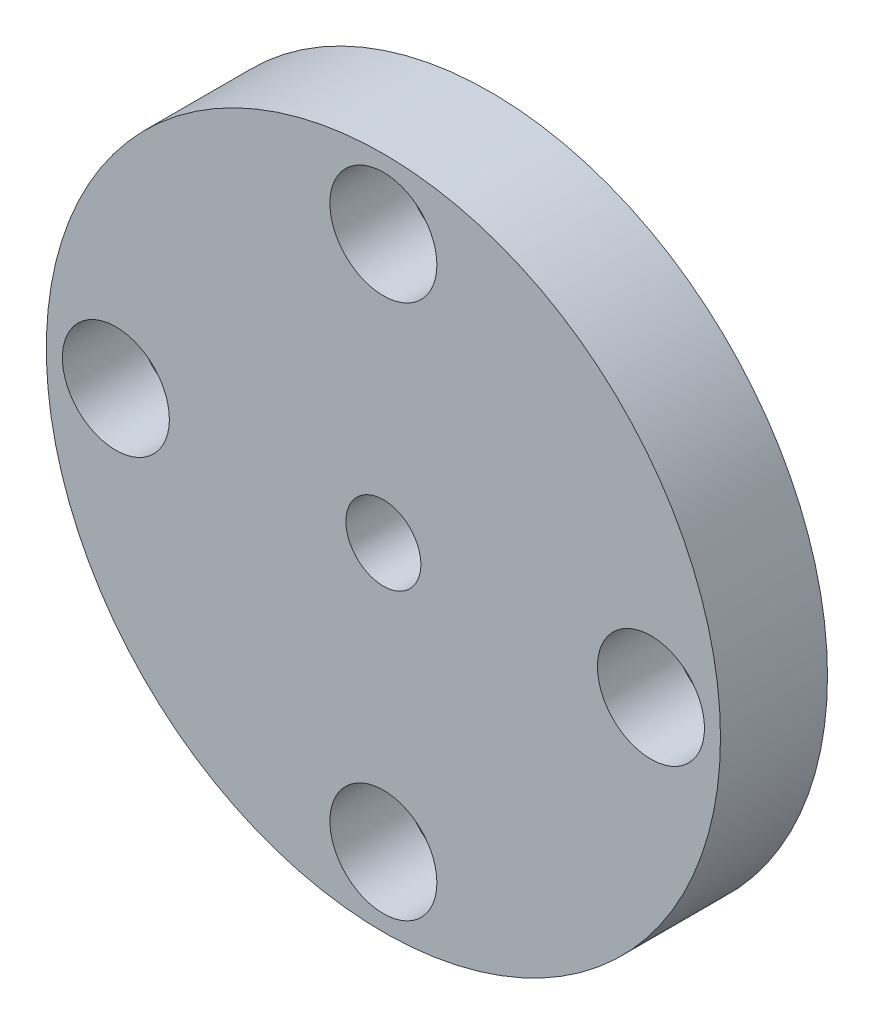
from build123d import *

# Parameters (mm, degrees)
SKETCH1_R               = 31.5
BOSS_EXTRUDE1_DEPTH     = 10
SKETCH1_3_R             = 15.5
BOSS_EXTRUDE2_DEPTH     = 4
SKETCH2_R               = 3.5
CUT_EXTRUDE1_DEPTH      = 47.695824224
SKETCH3_R               = 5
SKETCH3_R_2             = 3
CUT_EXTRUDE2_DEPTH      = 7
CUT_EXTRUDE3_DEPTH      = 47.695824224
CUT_EXTRUDE3_DEPTH_BACK = 47.695824224
SKETCH3_4_R             = 3


with BuildPart() as part:
    # Sketch1 → Boss-Extrude1 (new body)
    with BuildSketch(Plane.XY):
        Circle(SKETCH1_R)
    extrude(amount=BOSS_EXTRUDE1_DEPTH)

    # Sketch1_3 → Boss-Extrude2 (add)
    with BuildSketch(Plane.XY):
        Circle(SKETCH1_3_R)
    extrude(amount=-BOSS_EXTRUDE2_DEPTH)

    # Sketch2 → Cut-Extrude1 (cut, through all)
    with BuildSketch(Plane(origin=(0, 0, -4), x_dir=(-1, 0, 0), z_dir=(0, 0, -1))):
        Circle(SKETCH2_R)
    extrude(amount=-CUT_EXTRUDE1_DEPTH, mode=Mode.SUBTRACT)

    # Sketch3 → Cut-Extrude2 (cut)
    # profile 1 of 4: a face of its own
    with BuildSketch(Plane.XY.offset(10)):
        with Locations((25, 0)):
            Circle(SKETCH3_R)
    # profile 2 of 4: a face of its own
    with BuildSketch(Plane.XY.offset(10)):
        with Locations((0, 25)):
            Circle(SKETCH3_R)
        with Locations((0, 25)):
            Circle(SKETCH3_R_2, mode=Mode.SUBTRACT)
    # profile 3 of 4: a face of its own
    with BuildSketch(Plane.XY.offset(10)):
        with Locations((0, -25)):
            Circle(SKETCH3_R)
        with Locations((0, -25)):
            Circle(SKETCH3_R_2, mode=Mode.SUBTRACT)
    # profile 4 of 4: a face of its own
    with BuildSketch(Plane.XY.offset(10)):
        with Locations((-25, 0)):
            Circle(SKETCH3_R)
        with Locations((-25, 0)):
            Circle(SKETCH3_R_2, mode=Mode.SUBTRACT)
    extrude(amount=-CUT_EXTRUDE2_DEPTH, mode=Mode.SUBTRACT)

    # Sketch3_4 → Cut-Extrude3 (cut, two sides: drawn at the far end of the back side and taken through both)
    with BuildSketch(Plane.XY.offset(10).offset(-CUT_EXTRUDE3_DEPTH_BACK)):
        with Locations((25, 0)):
            Circle(SKETCH3_4_R)
        with Locations((0, 25)):
            Circle(SKETCH3_4_R)
        with Locations((0, -25)):
            Circle(SKETCH3_4_R)
        with Locations((-25, 0)):
            Circle(SKETCH3_4_R)
    extrude(amount=CUT_EXTRUDE3_DEPTH + CUT_EXTRUDE3_DEPTH_BACK, mode=Mode.SUBTRACT)


solid = part.part
